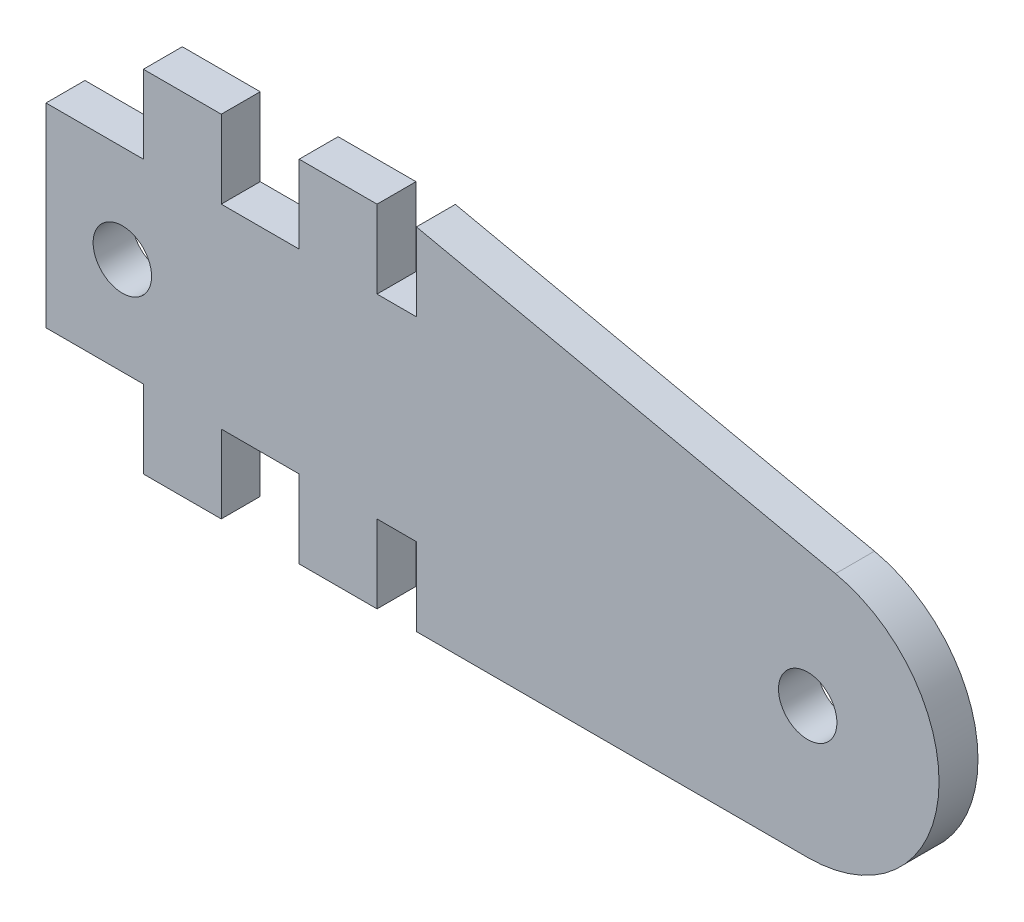
from build123d import *

# Parameters (mm, degrees)
SKETCH1_R           = 1.5
BOSS_EXTRUDE1_DEPTH = 2


with BuildPart() as part:
    # Sketch1 → Boss-Extrude1 (new body)
    with BuildSketch(Plane.XY):
        with BuildLine():
            Line((5, 0), (9, 0))
            Line((9, 0), (9, 4))
            Line((9, 4), (13, 4))
            Line((13, 4), (13, 0))
            Line((13, 0), (17, 0))
            Line((17, 0), (17, 4))
            Line((17, 4), (19.021561934, 4))
            Line((19.021561934, 4), (19.021561934, 0))
            Line((19.021561934, 0), (39.114495851, 0))
            ThreePointArc((39.114495851, 0), (45.821499943, 6.027186123), (40.542646089, 13.337766021))
            Line((40.542646089, 13.337766021), (19.021561934, 17.999988357))
            Line((19.021561934, 17.999988357), (19.021561934, 13.999988357))
            Line((19.021561934, 13.999988357), (17, 13.999988357))
            Line((17, 13.999988357), (17, 17.999988357))
            Line((17, 17.999988357), (13, 17.999988357))
            Line((13, 17.999988357), (13, 13.999988357))
            Line((13, 13.999988357), (9, 13.999988357))
            Line((9, 13.999988357), (9, 17.999988357))
            Line((9, 17.999988357), (5, 17.999988357))
            Line((5, 17.999988357), (5, 13.999988357))
            Line((5, 13.999988357), (0, 13.999988357))
            Line((0, 13.999988357), (0, 4))
            Line((0, 4), (5, 4))
            Line((5, 4), (5, 0))
        make_face()
        with Locations((3.920490093, 9)):
            Circle(SKETCH1_R, mode=Mode.SUBTRACT)
        with Locations((39.114495851, 6.745343083)):
            Circle(SKETCH1_R, mode=Mode.SUBTRACT)
    extrude(amount=BOSS_EXTRUDE1_DEPTH)


solid = part.part
